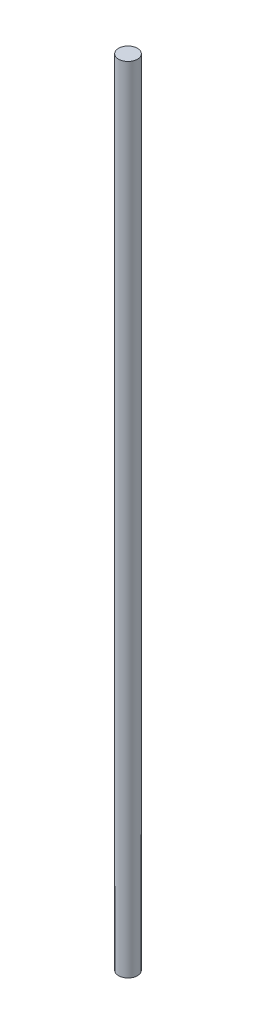
from build123d import *

# Parameters (mm, degrees)
SKETCH1_R           = 4.7625
BOSS_EXTRUDE1_DEPTH = 400


with BuildPart() as part:
    # Sketch1 → Boss-Extrude1 (new body)
    with BuildSketch(Plane(origin=(0, 0, 0), x_dir=(1, 0, 0), z_dir=(0, 1, 0))):
        Circle(SKETCH1_R)
    extrude(amount=BOSS_EXTRUDE1_DEPTH)


solid = part.part
